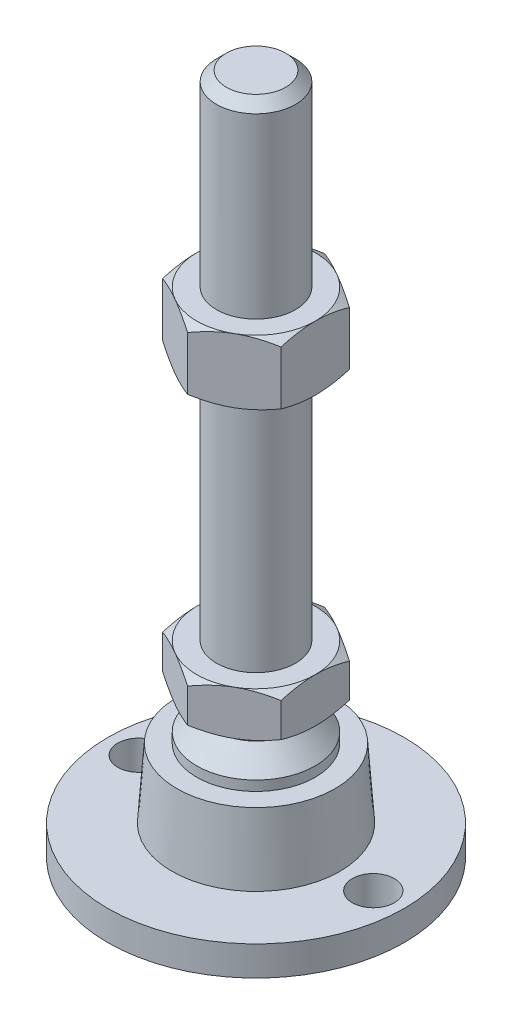
from build123d import *

# Parameters (mm, degrees)
EXTRUDE_1_DEPTH     = 9
EXTRUDE_2_DEPTH     = 13
SKETCH_5_R          = 4.25
CUT_EXTRUDE_1_DEPTH = 7


with BuildPart() as part:
    # Эскиз1 → Повернуть1 (revolve)
    with BuildSketch(Plane.XY, mode=Mode.PRIVATE) as revolve_1_sk:
        Polygon((0, 0), (-30, 0), (-30, 6), (-17, 6), (-16, 20), (-12, 20), (-12, 22), (-8, 26), (-8, 29), (-8, 38), (-8, 136), (-6, 138), (0, 138), align=None)
    revolve(revolve_1_sk.sketch.rotate(Axis((0, 0, 0), (0, 1, 0)), 180), axis=Axis((0, 0, 0), (0, 1, 0)))  # turned: the seam where the file's is

    # Эскиз2 → Бобышка-Вытянуть1 (add)
    with BuildSketch(Plane(origin=(0, 29, 0), x_dir=(1, 0, 0), z_dir=(0, 1, 0))):
        Polygon((0, 13.856406461), (-12, 6.92820323), (-12, -6.92820323), (0, -13.856406461), (12, -6.92820323), (12, 6.92820323), align=None)
    extrude(amount=EXTRUDE_1_DEPTH)

    # Эскиз3 → Бобышка-Вытянуть2 (add)
    with BuildSketch(Plane(origin=(0, 87, 0), x_dir=(1, 0, 0), z_dir=(0, 1, 0))):
        Polygon((12, 6.92820323), (0, 13.856406461), (-12, 6.92820323), (-12, -6.92820323), (0, -13.856406461), (12, -6.92820323), align=None)
    extrude(amount=EXTRUDE_2_DEPTH)

    # Эскиз4 → Вырез-Повернуть2 (revolve, cut)
    with BuildSketch(Plane.XY, mode=Mode.PRIVATE) as cut_revolve_2_sk:
        Polygon((-23.258330249, 100), (-12, 100), (-23.258330249, 93.5), align=None)
        Polygon((-23.258330249, 87), (-23.258330249, 93.5), (-12, 87), align=None)
        Polygon((-19.794228634, 38), (-19.794228634, 33.5), (-12, 38), align=None)
        Polygon((-19.794228634, 33.5), (-19.794228634, 29), (-12, 29), align=None)
    revolve(cut_revolve_2_sk.sketch.rotate(Axis((0, 138, 0), (0, -1, 0)), 180), axis=Axis((0, 138, 0), (0, -1, 0)), mode=Mode.SUBTRACT)  # turned: the seam where the file's is

    # Эскиз5 → Вырез-Вытянуть1 (cut, through all)
    with BuildSketch(Plane(origin=(0, 6, 0), x_dir=(1, 0, 0), z_dir=(0, 1, 0))):
        with Locations(Location((-23.75, 0, 0), (0, 0, 180))):  # turned: the seam where the file's is
            Circle(SKETCH_5_R)
        with Locations(Location((23.75, 0, 0), (0, 0, 180))):  # turned: the seam where the file's is
            Circle(SKETCH_5_R)
    extrude(amount=-CUT_EXTRUDE_1_DEPTH, mode=Mode.SUBTRACT)


solid = part.part
